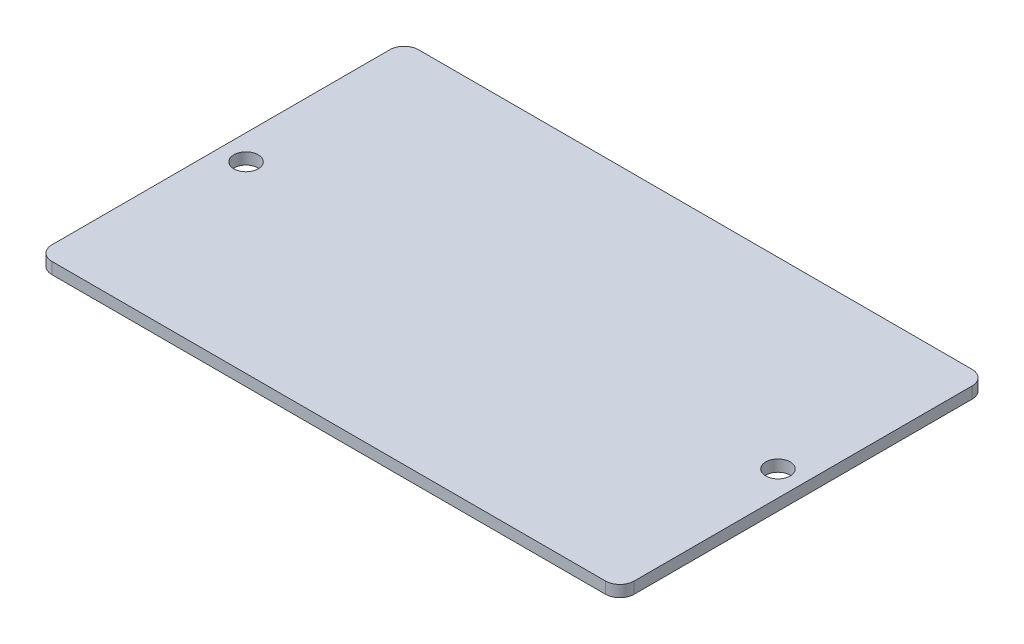
from build123d import *

# Parameters (mm, degrees)
SKETCH1_W           = 81
SKETCH1_H           = 51
SKETCH1_R           = 1.7
BOSS_EXTRUDE1_DEPTH = 1.6
FILLET1_R           = 2


with BuildPart() as part:
    # Sketch1 → Boss-Extrude1 (new body)
    with BuildSketch(Plane(origin=(0, 0, 0), x_dir=(1, 0, 0), z_dir=(0, 1, 0))):
        Rectangle(SKETCH1_W, SKETCH1_H)
        with Locations((-37, 0)):
            Circle(SKETCH1_R, mode=Mode.SUBTRACT)
        with Locations((37, 0)):
            Circle(SKETCH1_R, mode=Mode.SUBTRACT)
    extrude(amount=BOSS_EXTRUDE1_DEPTH)

    # Fillet1
    fillet1_edges = [part.edges().sort_by_distance(p)[0] for p in [
        (-40.5, 0.8, -25.5),
        (40.5, 0.8, -25.5),
        (40.5, 0.8, 25.5),
        (-40.5, 0.8, 25.5),
    ]]
    fillet(fillet1_edges, radius=FILLET1_R)


solid = part.part
